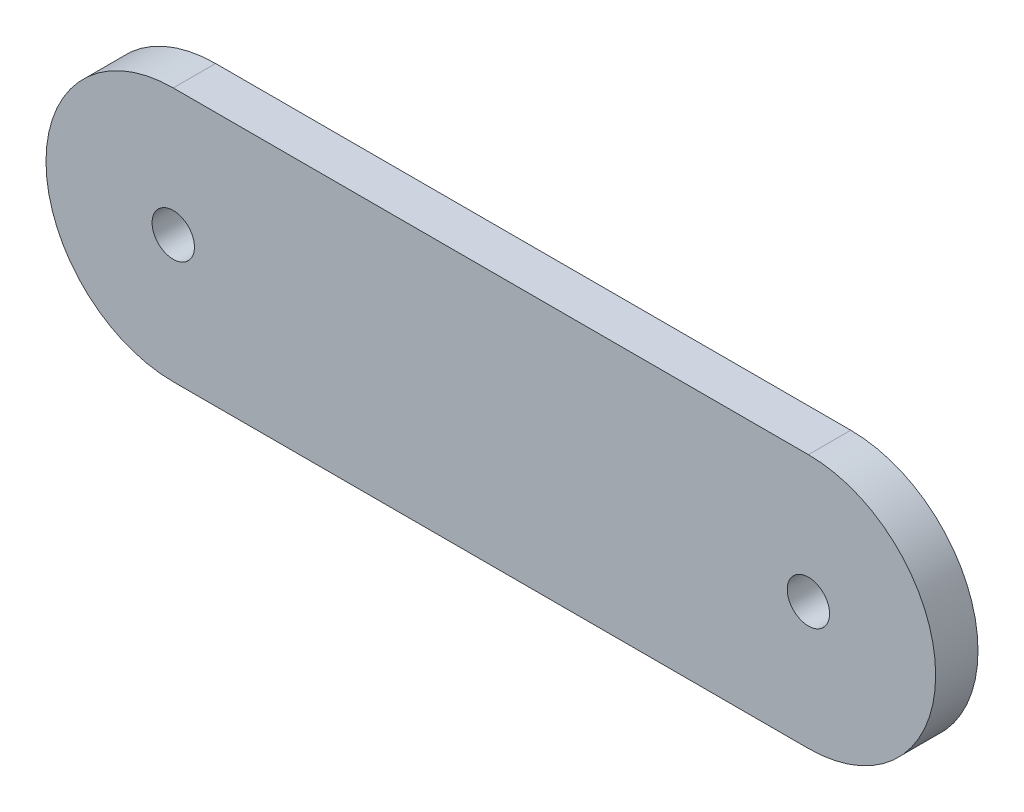
from build123d import *

# Parameters (mm, degrees)
SKETCH1_R           = 1
BOSS_EXTRUDE1_DEPTH = 2


with BuildPart() as part:
    # Sketch1 → Boss-Extrude1 (new body)
    with BuildSketch(Plane.XY):
        with BuildLine():
            Line((-15, 6.009754879), (15, 6.009754879))
            ThreePointArc((15, 6.009754879), (21.009754879, 0), (15, -6.009754879))
            Line((15, -6.009754879), (-15, -6.009754879))
            ThreePointArc((-15, -6.009754879), (-21.009754879, 0), (-15, 6.009754879))
        make_face()
        with Locations((-15, 0)):
            Circle(SKETCH1_R, mode=Mode.SUBTRACT)
        with Locations((15, 0)):
            Circle(SKETCH1_R, mode=Mode.SUBTRACT)
    extrude(amount=BOSS_EXTRUDE1_DEPTH)


solid = part.part
